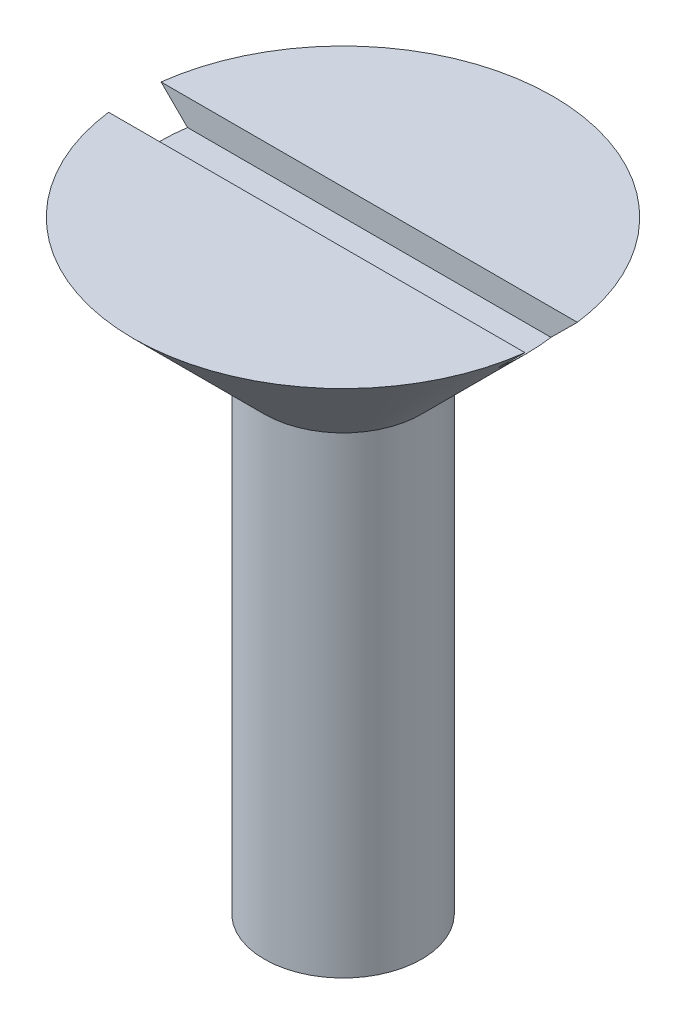
from build123d import *

# Parameters (mm, degrees)
CUT_EXTRUDE1_DEPTH = 9


with BuildPart() as part:
    # Sketch1 → Revolve1 (revolve)
    with BuildSketch(Plane.XY):
        Polygon((0, 9), (0, -9), (0, -10.732050808), (3, -9), (3, 9), (8, 14), (0, 14), align=None)
    revolve(axis=Axis((0, 9, 0), (0, -1, 0)))

    # Sketch2 → Cut-Extrude1 (cut, symmetric)
    with BuildSketch(Plane(origin=(0, 0, 0), x_dir=(0, 0, -1), z_dir=(1, 0, 0))):
        Polygon((0, 14), (1, 14), (1, 13), (-1, 13), (-1, 14), align=None)
    extrude(amount=CUT_EXTRUDE1_DEPTH, both=True, mode=Mode.SUBTRACT)


solid = part.part
